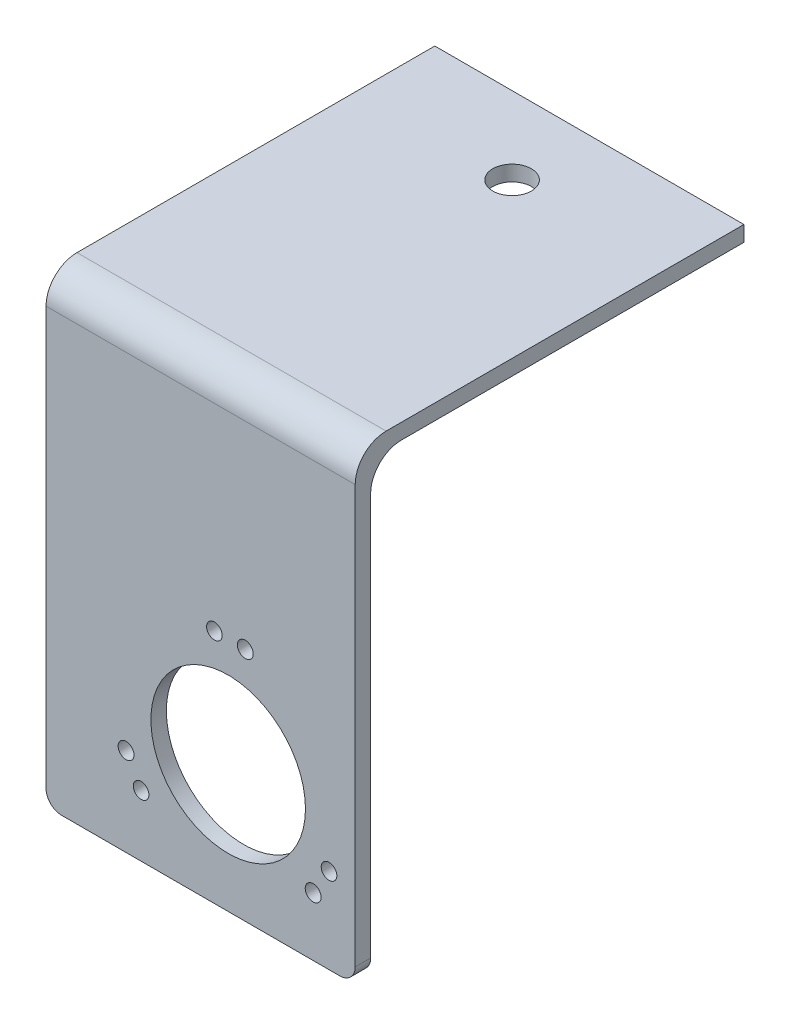
from build123d import *

# Parameters (mm, degrees)
SKETCH1_W           = 40
SKETCH1_H           = 42
BOSS_EXTRUDE1_DEPTH = 2
SKETCH3_W           = 40
SKETCH3_H           = 2
BOSS_EXTRUDE2_DEPTH = 48.3
FILLET1_R           = 2
FILLET2_R           = 2
CUT_EXTRUDE5_REACH  = 52.3
SKETCH7_R           = 1.008522139
SKETCH7_R_2         = 1.026344308
SKETCH7_R_3         = 1.008522138
SKETCH7_R_4         = 10
CUT_EXTRUDE6_REACH  = 4
SKETCH4_R           = 2.5
SKETCH8_W           = 40
SKETCH8_H           = 50.3
SKETCH8_R           = 2.5
BOSS_EXTRUDE3_DEPTH = 18.05
SKETCH10_W          = 40
SKETCH10_H          = 6.748630519
BOSS_EXTRUDE5_DEPTH = 17.05
SKETCH11_W          = 40
SKETCH11_H          = 46.3
CUT_EXTRUDE7_DEPTH  = 18.05
SKETCH12_W          = 40
SKETCH12_H          = 2
CUT_EXTRUDE8_DEPTH  = 22.05
SKETCH13_W          = 2
SKETCH13_H          = 2
BOSS_EXTRUDE6_DEPTH = 40
FILLET3_R           = 4
FILLET4_R           = 4


with BuildPart() as part:
    # Sketch1 → Boss-Extrude1 (new body)
    with BuildSketch(Plane.XY):
        Rectangle(SKETCH1_W, SKETCH1_H)
    extrude(amount=BOSS_EXTRUDE1_DEPTH)

    # Sketch3 → Boss-Extrude2 (add)
    with BuildSketch(Plane(origin=(0, 0, 0), x_dir=(-1, 0, 0), z_dir=(0, 0, -1))):
        with Locations((0, 20)):
            Rectangle(SKETCH3_W, SKETCH3_H)
    extrude(amount=BOSS_EXTRUDE2_DEPTH)

    # Fillet1
    fillet1_edges = [part.edges().sort_by_distance(p)[0] for p in [
        (0, 19, 0),
        (0, 21, 2),
    ]]
    fillet(fillet1_edges, radius=FILLET1_R)

    # Fillet2
    fillet2_edges = [part.edges().sort_by_distance(p)[0] for p in [
        (20, -21, 1),
        (-20, -21, 1),
    ]]
    fillet(fillet2_edges, radius=FILLET2_R)

    # Sketch7 → Cut-Extrude5 (cut, up to next)
    with BuildSketch(Plane.XY.offset(2), mode=Mode.PRIVATE) as cut_extrude5_sk1:
        with Locations((-7.700271416, -13.062366093)):
            Circle(SKETCH7_R)
    cut_extrude5_tool1 = extrude(cut_extrude5_sk1.sketch, amount=-CUT_EXTRUDE5_REACH, mode=Mode.PRIVATE) & part.part
    add(cut_extrude5_tool1.solids().sort_by_distance((-7.700271, -13.062366, 2))[0], mode=Mode.SUBTRACT)
    # Sketch7 → Cut-Extrude5 (cut, up to next)
    with BuildSketch(Plane.XY.offset(2), mode=Mode.PRIVATE) as cut_extrude5_sk2:
        with Locations((-9.646314877, -9.567667988)):
            Circle(SKETCH7_R_2)
    cut_extrude5_tool2 = extrude(cut_extrude5_sk2.sketch, amount=-CUT_EXTRUDE5_REACH, mode=Mode.PRIVATE) & part.part
    add(cut_extrude5_tool2.solids().sort_by_distance((-9.646315, -9.567668, 2))[0], mode=Mode.SUBTRACT)
    # Sketch7 → Cut-Extrude5 (cut, up to next)
    with BuildSketch(Plane.XY.offset(2), mode=Mode.PRIVATE) as cut_extrude5_sk3:
        with Locations((1.782545423, 9.537272948)):
            Circle(SKETCH7_R_3)
    cut_extrude5_tool3 = extrude(cut_extrude5_sk3.sketch, amount=-CUT_EXTRUDE5_REACH, mode=Mode.PRIVATE) & part.part
    add(cut_extrude5_tool3.solids().sort_by_distance((1.782545, 9.537273, 2))[0], mode=Mode.SUBTRACT)
    # Sketch7 → Cut-Extrude5 (cut, up to next)
    with BuildSketch(Plane.XY.offset(2), mode=Mode.PRIVATE) as cut_extrude5_sk4:
        with Locations((5.782064491, 9.475246969)):
            Circle(SKETCH7_R_2)
    cut_extrude5_tool4 = extrude(cut_extrude5_sk4.sketch, amount=-CUT_EXTRUDE5_REACH, mode=Mode.PRIVATE) & part.part
    add(cut_extrude5_tool4.solids().sort_by_distance((5.782064, 9.475247, 2))[0], mode=Mode.SUBTRACT)
    # Sketch7 → Cut-Extrude5 (cut, up to next)
    with BuildSketch(Plane.XY.offset(2), mode=Mode.PRIVATE) as cut_extrude5_sk5:
        with Locations((3.565090845, -4.5)):
            Circle(SKETCH7_R_4)
    cut_extrude5_tool5 = extrude(cut_extrude5_sk5.sketch, amount=-CUT_EXTRUDE5_REACH, mode=Mode.PRIVATE) & part.part
    add(cut_extrude5_tool5.solids().sort_by_distance((3.565091, -4.5, 2))[0], mode=Mode.SUBTRACT)
    # Sketch7 → Cut-Extrude5 (cut, up to next)
    with BuildSketch(Plane.XY.offset(2), mode=Mode.PRIVATE) as cut_extrude5_sk6:
        with Locations((16.612998529, -9.974906855)):
            Circle(SKETCH7_R)
    cut_extrude5_tool6 = extrude(cut_extrude5_sk6.sketch, amount=-CUT_EXTRUDE5_REACH, mode=Mode.PRIVATE) & part.part
    add(cut_extrude5_tool6.solids().sort_by_distance((16.612999, -9.974907, 2))[0], mode=Mode.SUBTRACT)
    # Sketch7 → Cut-Extrude5 (cut, up to next)
    with BuildSketch(Plane.XY.offset(2), mode=Mode.PRIVATE) as cut_extrude5_sk7:
        with Locations((14.559522922, -13.407578981)):
            Circle(SKETCH7_R_2)
    cut_extrude5_tool7 = extrude(cut_extrude5_sk7.sketch, amount=-CUT_EXTRUDE5_REACH, mode=Mode.PRIVATE) & part.part
    add(cut_extrude5_tool7.solids().sort_by_distance((14.559523, -13.407579, 2))[0], mode=Mode.SUBTRACT)

    # Sketch4 → Cut-Extrude6 (cut, up to next)
    with BuildSketch(Plane.XZ.offset(-19), mode=Mode.PRIVATE) as cut_extrude6_sk1:
        with Locations((0, -38.3)):
            Circle(SKETCH4_R)
    cut_extrude6_tool1 = extrude(cut_extrude6_sk1.sketch, amount=-CUT_EXTRUDE6_REACH, mode=Mode.PRIVATE) & part.part
    add(cut_extrude6_tool1.solids().sort_by_distance((0, 19, -38.3))[0], mode=Mode.SUBTRACT)

    # Sketch8 → Boss-Extrude3 (add)
    with BuildSketch(Plane(origin=(0, 21, 0), x_dir=(1, 0, 0), z_dir=(0, 1, 0))):
        with Locations((0, 23.15)):
            Rectangle(SKETCH8_W, SKETCH8_H)
        with Locations((0, 38.3)):
            Circle(SKETCH8_R, mode=Mode.SUBTRACT)
    extrude(amount=BOSS_EXTRUDE3_DEPTH)

    # Sketch10 → Boss-Extrude5 (add)
    with BuildSketch(Plane.XY.offset(2)):
        with Locations((0, 22.37431526)):
            Rectangle(SKETCH10_W, SKETCH10_H)
    extrude(amount=-BOSS_EXTRUDE5_DEPTH)

    # Sketch11 → Cut-Extrude7 (cut)
    with BuildSketch(Plane.XZ.offset(-19)):
        with Locations((0, -25.15)):
            Rectangle(SKETCH11_W, SKETCH11_H)
    extrude(amount=-CUT_EXTRUDE7_DEPTH, mode=Mode.SUBTRACT)

    # Sketch12 → Cut-Extrude8 (cut)
    with BuildSketch(Plane(origin=(0, 39.05, 0), x_dir=(1, 0, 0), z_dir=(0, 1, 0))):
        with Locations((0, 1)):
            Rectangle(SKETCH12_W, SKETCH12_H)
    extrude(amount=-CUT_EXTRUDE8_DEPTH, mode=Mode.SUBTRACT)

    # Sketch13 → Boss-Extrude6 (add)
    with BuildSketch(Plane(origin=(20, 0, 0), x_dir=(0, 0, -1), z_dir=(1, 0, 0))):
        with Locations((1, 38.05)):
            Rectangle(SKETCH13_W, SKETCH13_H)
    extrude(amount=-BOSS_EXTRUDE6_DEPTH)

    # Fillet3
    fillet3_edges = [part.edges().sort_by_distance(p)[0] for p in [
        (0, 39.05, 2),
    ]]
    fillet(fillet3_edges, radius=FILLET3_R)

    # Fillet4
    fillet4_edges = [part.edges().sort_by_distance(p)[0] for p in [
        (0, 37.05, 0),
    ]]
    fillet(fillet4_edges, radius=FILLET4_R)


solid = part.part
